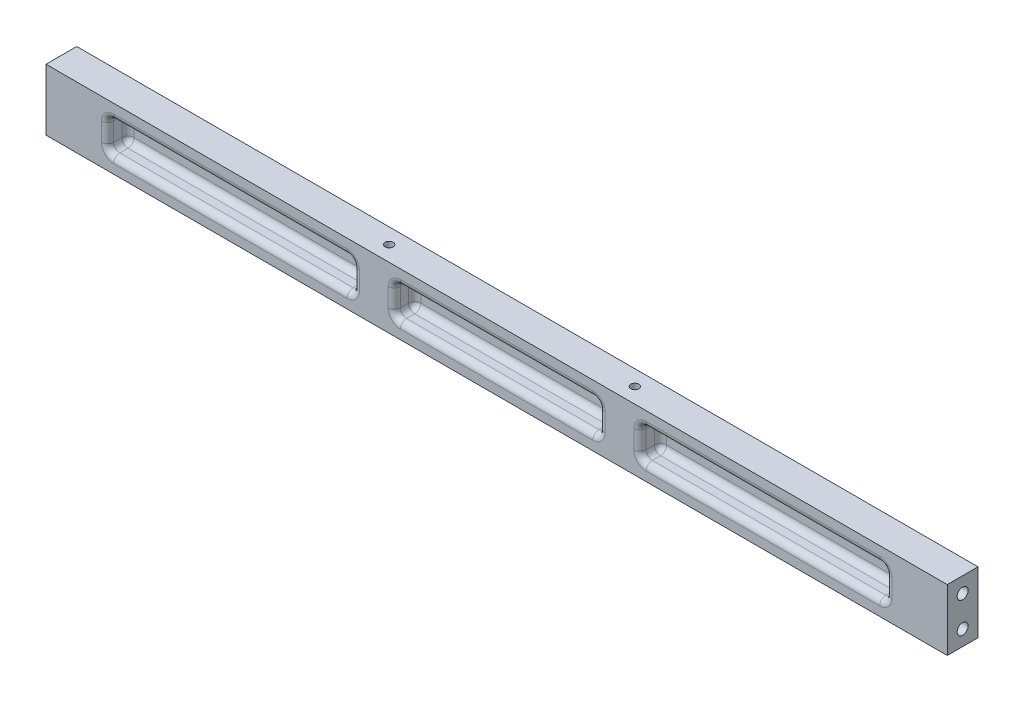
from build123d import *

# Parameters (mm, degrees)
SKETCH1_W                  = 558.8
SKETCH1_H                  = 38.1
EXTRUDE1_DEPTH             = 9.525
M8X1_25_TAPPED_HOLE1_D     = 6.8
M8X1_25_TAPPED_HOLE1_DEPTH = 19.812
M8X1_25_TAPPED_HOLE1_TIP   = 2.042926105
M8X1_25_TAPPED_HOLE2_D     = 6.8
M8X1_25_TAPPED_HOLE2_DEPTH = 19.812
M8X1_25_TAPPED_HOLE2_TIP   = 2.042926105
M6X1_0_TAPPED_HOLE1_D      = 5
M6X1_0_TAPPED_HOLE1_DEPTH  = 12.7
M6X1_0_TAPPED_HOLE1_TIP    = 1.502151548
SKETCH12_W                 = 127
SKETCH12_H                 = 19.05
SKETCH12_W_2               = 152.4
CUT_EXTRUDE1_DEPTH         = 12.7
FILLET1_R                  = 3.81


with BuildPart() as part:
    # Sketch1 → Extrude1 (new body, symmetric)
    with BuildSketch(Plane.XY):
        Rectangle(SKETCH1_W, SKETCH1_H)
    extrude(amount=EXTRUDE1_DEPTH, both=True)

    # M8x1.25 Tapped Hole1
    with Locations(Plane.ZY.offset(279.4)):
        with Locations((0, 9.525), (0, -9.525)):
            Hole(M8X1_25_TAPPED_HOLE1_D / 2, depth=M8X1_25_TAPPED_HOLE1_DEPTH)
            with Locations((0, 0, -(M8X1_25_TAPPED_HOLE1_DEPTH + M8X1_25_TAPPED_HOLE1_TIP / 2))):  # 118° drill point
                Cone(0, M8X1_25_TAPPED_HOLE1_D / 2, M8X1_25_TAPPED_HOLE1_TIP, mode=Mode.SUBTRACT)

    # M8x1.25 Tapped Hole2
    with Locations(Plane(origin=(279.4, 0, 0), x_dir=(0, 0, -1), z_dir=(1, 0, 0))):
        with Locations((0, 9.525), (0, -9.525)):
            Hole(M8X1_25_TAPPED_HOLE2_D / 2, depth=M8X1_25_TAPPED_HOLE2_DEPTH)
            with Locations((0, 0, -(M8X1_25_TAPPED_HOLE2_DEPTH + M8X1_25_TAPPED_HOLE2_TIP / 2))):  # 118° drill point
                Cone(0, M8X1_25_TAPPED_HOLE2_D / 2, M8X1_25_TAPPED_HOLE2_TIP, mode=Mode.SUBTRACT)

    # M6x1.0 Tapped Hole1
    with Locations(Plane(origin=(0, 19.05, 0), x_dir=(1, 0, 0), z_dir=(0, 1, 0))):
        with Locations((-76.2, 0), (76.2, 0)):
            Hole(M6X1_0_TAPPED_HOLE1_D / 2, depth=M6X1_0_TAPPED_HOLE1_DEPTH)
            with Locations((0, 0, -(M6X1_0_TAPPED_HOLE1_DEPTH + M6X1_0_TAPPED_HOLE1_TIP / 2))):  # 118° drill point
                Cone(0, M6X1_0_TAPPED_HOLE1_D / 2, M6X1_0_TAPPED_HOLE1_TIP, mode=Mode.SUBTRACT)

    # Sketch12 → Cut-Extrude1 (cut)
    with BuildSketch(Plane.XY.offset(9.525)):
        Rectangle(SKETCH12_W, SKETCH12_H)
        with Locations((165.1, 0)):
            Rectangle(SKETCH12_W_2, SKETCH12_H)
        with Locations((-165.1, 0)):
            Rectangle(SKETCH12_W_2, SKETCH12_H)
    extrude(amount=-CUT_EXTRUDE1_DEPTH, mode=Mode.SUBTRACT)

    # Fillet1
    fillet1_edges = [part.edges().sort_by_distance(p)[0] for p in [
        (-88.9, 0, -3.175),
        (-88.9, 9.525, 3.175),
        (-165.1, -9.525, -3.175),
        (-88.9, -9.525, 3.175),
        (-241.3, 0, -3.175),
        (-241.3, -9.525, 3.175),
        (-165.1, 9.525, -3.175),
        (-241.3, 9.525, 3.175),
        (-88.9, 0, 9.525),
        (-165.1, 9.525, 9.525),
        (-241.3, 0, 9.525),
        (-165.1, -9.525, 9.525),
        (241.3, 9.525, 3.175),
        (165.1, -9.525, -3.175),
        (241.3, -9.525, 3.175),
        (88.9, 0, -3.175),
        (88.9, -9.525, 3.175),
        (165.1, 9.525, -3.175),
        (88.9, 9.525, 3.175),
        (241.3, 0, 9.525),
        (165.1, 9.525, 9.525),
        (88.9, 0, 9.525),
        (165.1, -9.525, 9.525),
        (63.5, 0, -3.175),
        (63.5, 9.525, 3.175),
        (0, -9.525, -3.175),
        (63.5, -9.525, 3.175),
        (-63.5, 0, -3.175),
        (-63.5, -9.525, 3.175),
        (0, 9.525, -3.175),
        (-63.5, 9.525, 3.175),
        (63.5, 0, 9.525),
        (0, 9.525, 9.525),
        (-63.5, 0, 9.525),
        (0, -9.525, 9.525),
    ]]
    fillet(fillet1_edges, radius=FILLET1_R)


solid = part.part
